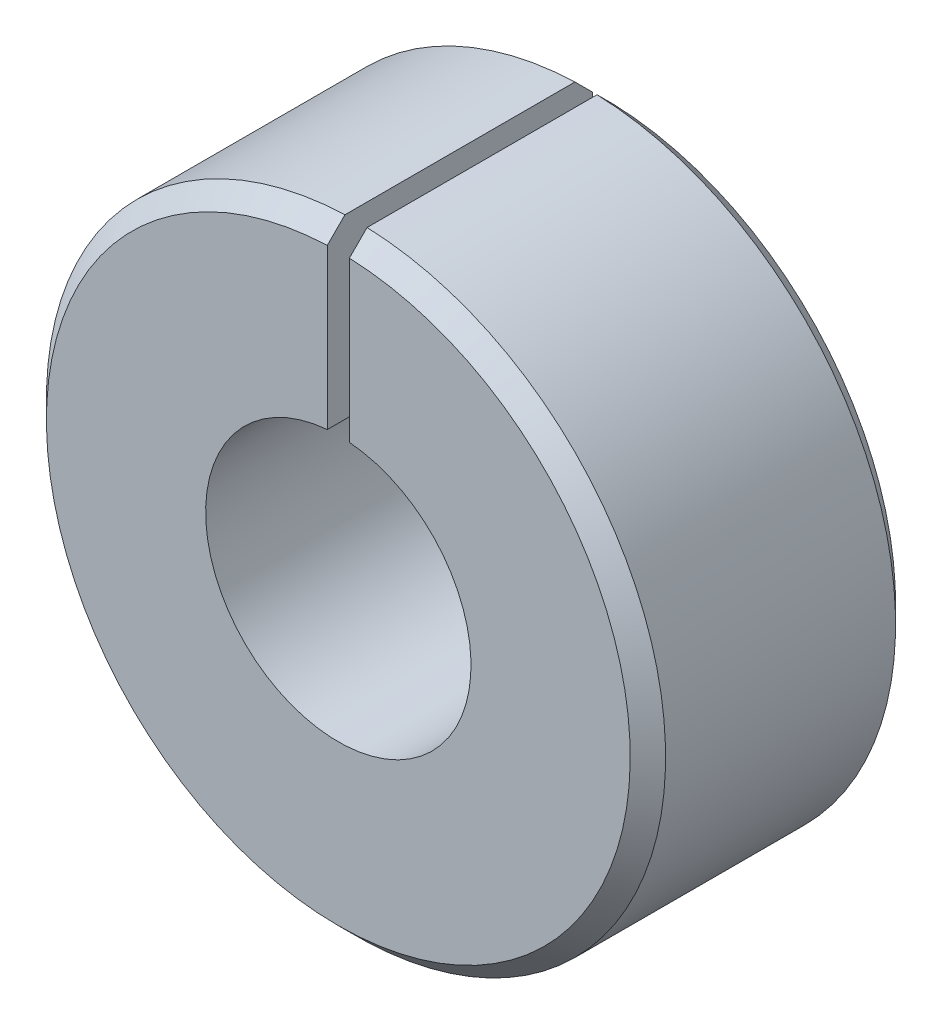
from build123d import *

# Parameters (mm, degrees)
EXTRUSION_DEPTH = 4.7625
CHAMFER1_SIZE   = 0.635


with BuildPart() as part:
    # profile → extrusion (new body, symmetric)
    with BuildSketch(Plane.XY):
        with BuildLine():
            Line((-0.396875, 4.745934732), (-0.396875, 11.105410685))
            ThreePointArc((-0.396875, 11.105410685), (0, -11.1125), (0.396875, 11.105410685))
            Line((0.396875, 11.105410685), (0.396875, 4.745934732))
            ThreePointArc((0.396875, 4.745934732), (0, -4.7625), (-0.396875, 4.745934732))
        make_face()
    extrude(amount=EXTRUSION_DEPTH, both=True)

    # Chamfer1
    chamfer1_edges = [part.edges().sort_by_distance(p)[0] for p in [
        (0, -11.1125, 4.7625),
        (0, -11.1125, -4.7625),
    ]]
    chamfer(chamfer1_edges, length=CHAMFER1_SIZE)


solid = part.part
